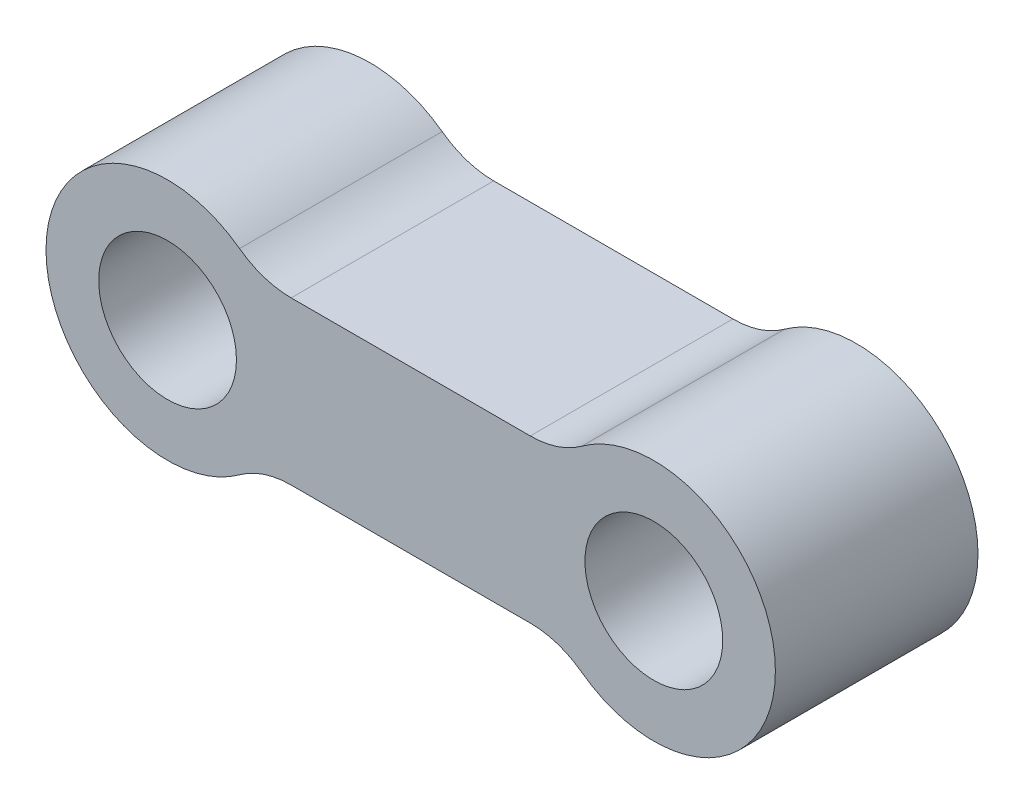
from build123d import *

# Parameters (mm, degrees)
CROQUIS1_R              = 4.25
SALIENTE_EXTRUIR1_DEPTH = 12.5


with BuildPart() as part:
    # Croquis1 → Saliente-Extruir1 (new body)
    with BuildSketch(Plane.XY):
        with BuildLine():
            Line((-7.377684836, -5), (7.377684836, -5))
            ThreePointArc((7.377684836, -5), (9.051224581, -5.267438742), (10.558069892, -6.04311649))
            ThreePointArc((10.558069892, -6.04311649), (22.5, 0), (10.558069892, 6.04311649))
            ThreePointArc((10.558069892, 6.04311649), (9.051224581, 5.267438742), (7.377684836, 5))
            Line((7.377684836, 5), (-7.377684836, 5))
            ThreePointArc((-7.377684836, 5), (-9.051224581, 5.267438742), (-10.558069892, 6.04311649))
            ThreePointArc((-10.558069892, 6.04311649), (-22.5, 0), (-10.558069892, -6.04311649))
            ThreePointArc((-10.558069892, -6.04311649), (-9.051224581, -5.267438742), (-7.377684836, -5))
        make_face()
        with Locations((-15, 0)):
            Circle(CROQUIS1_R, mode=Mode.SUBTRACT)
        with Locations((15, 0)):
            Circle(CROQUIS1_R, mode=Mode.SUBTRACT)
    extrude(amount=SALIENTE_EXTRUIR1_DEPTH)


solid = part.part
